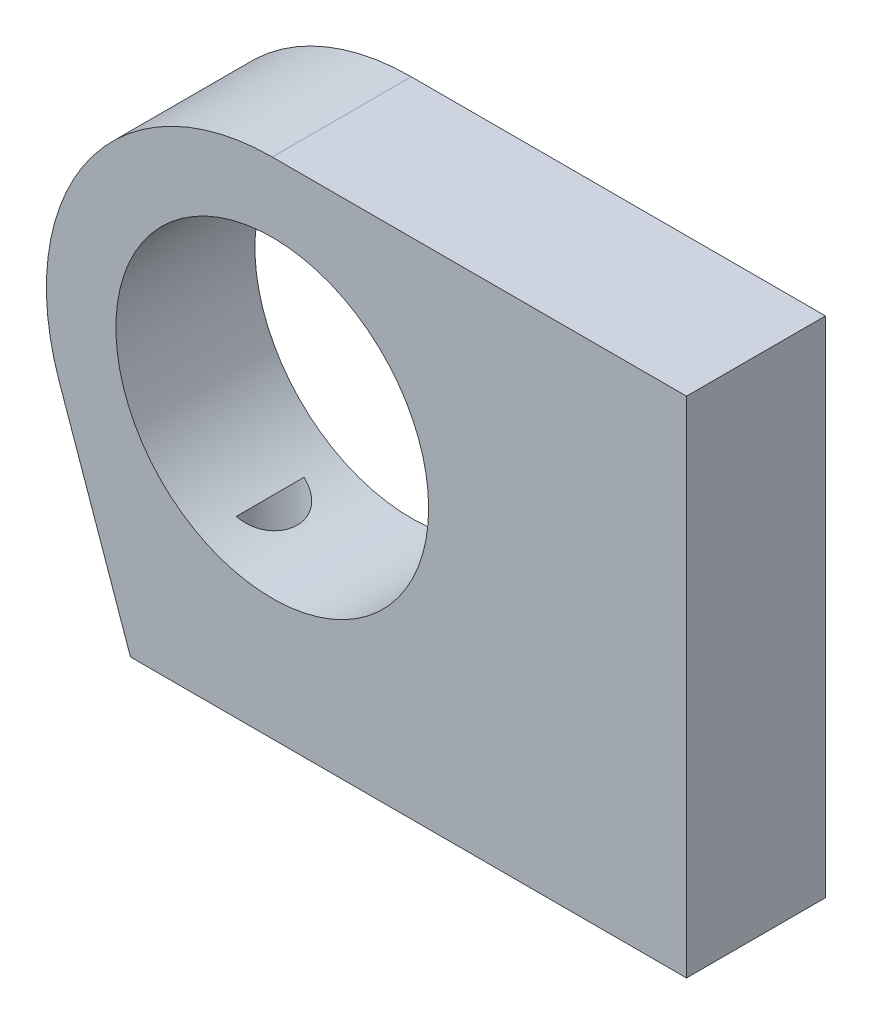
from build123d import *

# Parameters (mm, degrees)
SKETCH1_R           = 20.6375
SKETCH1_R_2         = 14.2875
BOSS_EXTRUDE2_DEPTH = 12.7
SKETCH2_R           = 3.175
CUT_EXTRUDE1_DEPTH  = 12.7


with BuildPart() as part:
    # Sketch1 → Boss-Extrude2 (new body)
    with BuildSketch(Plane.XY):
        with BuildLine():
            Line((-6.517989108, 18.562745695), (0, 0))
            Line((0, 0), (50.8, 0))
            Line((50.8, 0), (50.8, 46.0375))
            Line((50.8, 46.0375), (12.954, 46.0375))
            ThreePointArc((12.954, 46.0375), (27.546916197, 39.992916197), (33.5915, 25.4))
            ThreePointArc((33.5915, 25.4), (16.421941106, 5.055964247), (-6.517989108, 18.562745695))
        make_face()
        with Locations((12.954, 25.4)):
            Circle(SKETCH1_R)
        with Locations((12.954, 25.4)):
            Circle(SKETCH1_R_2, mode=Mode.SUBTRACT)
    extrude(amount=BOSS_EXTRUDE2_DEPTH)

    # Sketch2 → Cut-Extrude1 (cut)
    with BuildSketch(Plane.XZ):
        with Locations((45.085, 6.35)):
            Circle(SKETCH2_R)
        with Locations((5.715, 6.35)):
            Circle(SKETCH2_R)
    extrude(amount=-CUT_EXTRUDE1_DEPTH, mode=Mode.SUBTRACT)


solid = part.part
